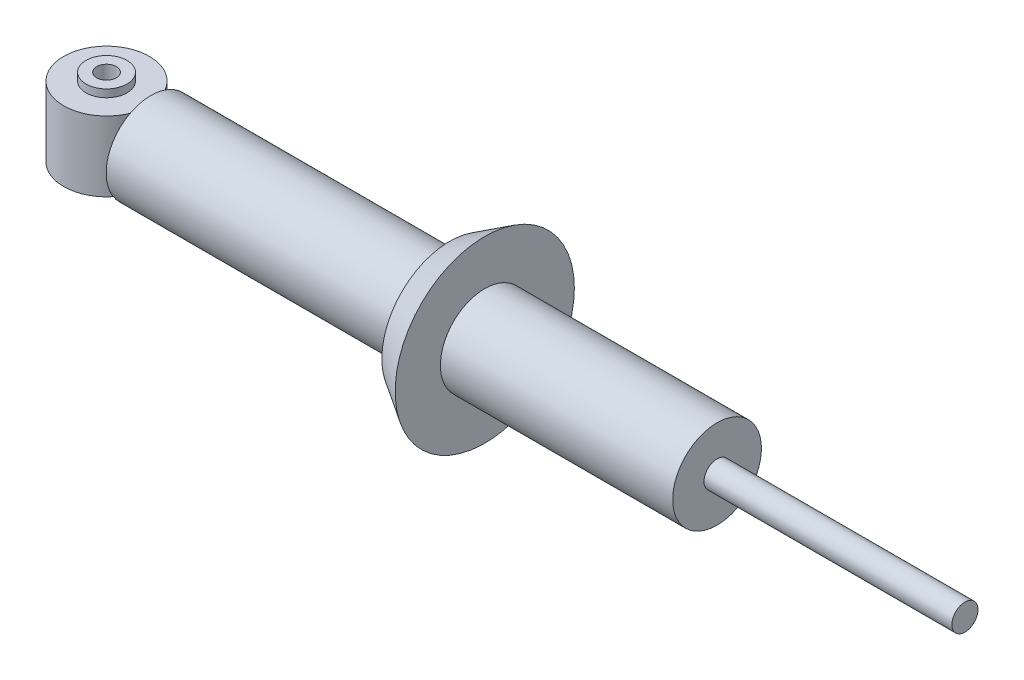
from build123d import *

# Parameters (mm, degrees)
SKETCH_2_R      = 26.2
EXTRUDE_1_DEPTH = 175
SKETCH_3_W      = 20
SKETCH_3_H      = 20
EXTRUDE_2_DEPTH = 3
SKETCH_4_R      = 39.7
SKETCH_5_R      = 52.5
SKETCH_6_R      = 26
EXTRUDE_3_DEPTH = 136.1
SKETCH_7_R      = 7.65
EXTRUDE_4_DEPTH = 145.23


with BuildPart() as part:
    # 草图1 → 旋转1 (revolve)
    with BuildSketch(Plane.XY):
        Polygon((-5.75, 25), (-12, 25), (-12, 20.5), (-25.1, 20.5), (-25.1, -20.5), (-12, -20.5), (-12, -25), (-5.75, -25), align=None)
    revolve(axis=Axis((0, 58.939420169, 0), (0, -1, 0)))

    # 草图3 → 凸台-拉伸2 (add)
    with BuildSketch(Plane(origin=(26, 0, 0), x_dir=(0, 0, -1), z_dir=(1, 0, 0))):
        Rectangle(SKETCH_3_W, SKETCH_3_H)
    extrude(amount=-EXTRUDE_2_DEPTH)


with BuildPart() as body_2:
    # 草图2 → 凸台-拉伸1 (new body)
    with BuildSketch(Plane(origin=(201, 0, 0), x_dir=(0, 0, -1), z_dir=(1, 0, 0))):
        Circle(SKETCH_2_R)
    extrude(amount=-EXTRUDE_1_DEPTH)

    # 草图4 → 放样2 section 0
    with BuildSketch(Plane(origin=(201, 0, 0), x_dir=(0, 0, -1), z_dir=(1, 0, 0))):
        Circle(SKETCH_4_R)
    # 草图5 → 放样2 section 1
    with BuildSketch(Plane(origin=(221.6, 0, 0), x_dir=(0, 0, -1), z_dir=(1, 0, 0))):
        Circle(SKETCH_5_R)
    loft()

    # 草图6 → 凸台-拉伸3 (add)
    with BuildSketch(Plane(origin=(221.6, 0, 0), x_dir=(0, 0, -1), z_dir=(1, 0, 0))):
        Circle(SKETCH_6_R)
    extrude(amount=EXTRUDE_3_DEPTH)

    # 草图7 → 凸台-拉伸4 (add)
    with BuildSketch(Plane(origin=(357.7, 0, 0), x_dir=(0, 0, -1), z_dir=(1, 0, 0))):
        Circle(SKETCH_7_R)
    extrude(amount=EXTRUDE_4_DEPTH)


solid = Compound([part.part, body_2.part])
